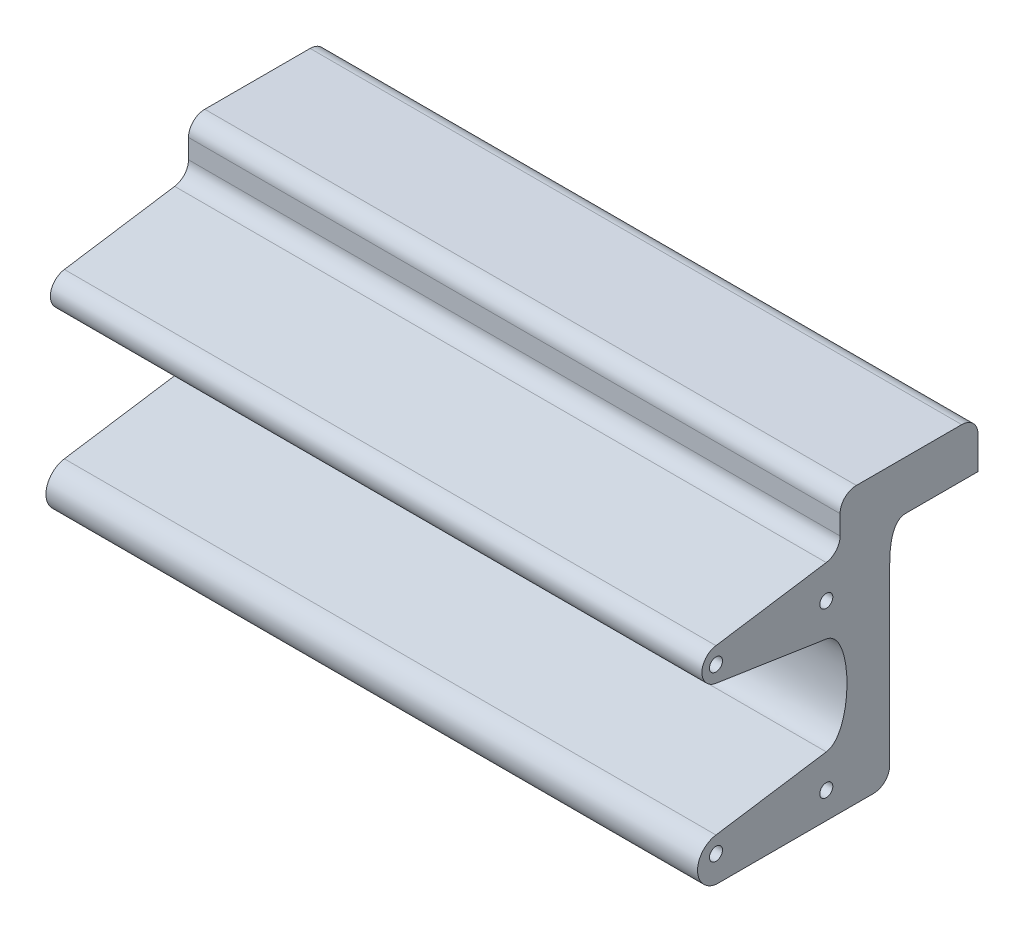
from build123d import *

# Parameters (mm, degrees)
SKETCH2_R           = 2
BOSS_EXTRUDE1_DEPTH = 100
FILLET1_R           = 5


with BuildPart() as part:
    # Sketch2 → Boss-Extrude1 (new body, symmetric)
    with BuildSketch(Plane(origin=(0, 0, 0), x_dir=(0, 0, -1), z_dir=(1, 0, 0))):
        with BuildLine():
            Line((11.05, 12.25), (-11.05, 12.25))
            Line((-11.05, 12.25), (-31.283333333, 12.25))
            Line((-31.283333333, 12.25), (-31.283333333, -2.985208333))
            Line((-31.283333333, -2.985208333), (-69.383333333, -8.788333333))
            ThreePointArc((-69.383333333, -8.788333333), (-73.686594127, -13.796666667), (-69.383333333, -18.805))
            Line((-69.383333333, -18.805), (-35.516666667, -23.963333333))
            add(Edge.make_bspline(
                [(-35.516666667, -23.963333333), (-27.05, -25.252916667), (-27.05, -52.67375), (-35.516666667, -53.963333333)],
                knots=[0, 0, 0, 0, 1, 1, 1, 1], degree=3))
            Line((-35.516666667, -53.963333333), (-69.383333333, -59.121666667))
            ThreePointArc((-69.383333333, -59.121666667), (-75.036285741, -65.700833333), (-69.383333333, -72.28))
            Line((-69.383333333, -72.28), (-31.283333333, -72.28))
            Line((-31.283333333, -72.28), (-16.05, -72.28))
            Line((-16.05, -72.28), (-16.05, -13.796666667))
            add(Edge.make_bspline(
                [(-11.05, -2.75), (-16.05, -2.75), (-16.05, -13.796666667)],
                knots=[0, 0, 0, 1, 1, 1], degree=2))
            Line((-11.05, -2.75), (11.05, -2.75))
            Line((11.05, -2.75), (11.05, 12.25))
        make_face()
        with Locations((-35.516666667, -13.796666667)):
            Circle(SKETCH2_R, mode=Mode.SUBTRACT)
        with Locations((-69.383333333, -13.796666667)):
            Circle(SKETCH2_R, mode=Mode.SUBTRACT)
        with Locations((-35.516666667, -64.121666667)):
            Circle(SKETCH2_R, mode=Mode.SUBTRACT)
        with Locations((-69.383333333, -64.121666667)):
            Circle(SKETCH2_R, mode=Mode.SUBTRACT)
    extrude(amount=BOSS_EXTRUDE1_DEPTH, both=True)

    # Fillet1
    fillet1_edges = [part.edges().sort_by_distance(p)[0] for p in [
        (0, -72.28, 16.05),
        (0, -2.985208333, 31.283333333),
        (0, 12.25, 31.283333333),
        (0, 12.25, -11.05),
    ]]
    fillet(fillet1_edges, radius=FILLET1_R)


solid = part.part
